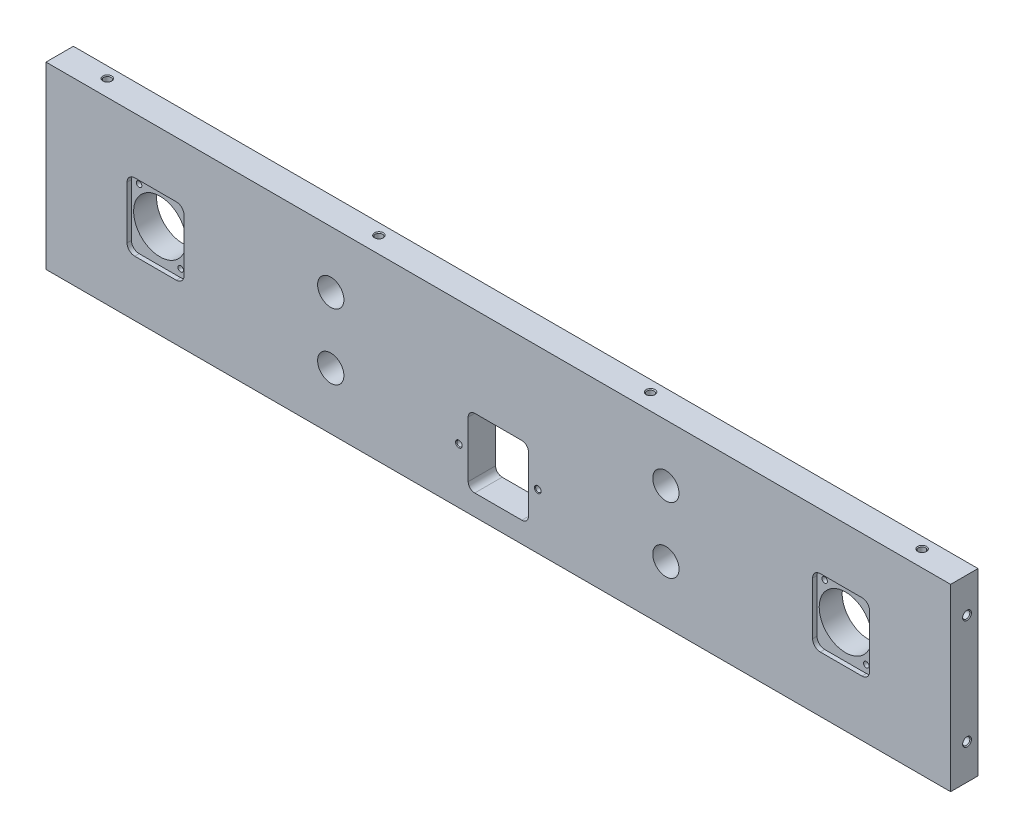
from build123d import *

# Parameters (mm, degrees)
SKETCH_1_W                   = 413
SKETCH_1_H                   = 82
EXTRUDE_1_DEPTH              = 12.5
SKETCH_2_R                   = 12
SKETCH_2_R_2                 = 6
SKETCH_2_W                   = 13.75
SKETCH_2_H                   = 31.5
CUT_EXTRUDE_1_DEPTH          = 13.5
HOLE_WIZARD_M3_1_D           = 2.5
HOLE_WIZARD_M3_1_CSINK_D     = 3.05
HOLE_WIZARD_M3_1_CSINK_ANGLE = 90
FILLET_1_R                   = 3
HOLE_WIZARD_M4_1_D           = 3.3
HOLE_WIZARD_M4_1_DEPTH       = 5
HOLE_WIZARD_M4_1_CSINK_D     = 4.05
HOLE_WIZARD_M4_1_CSINK_ANGLE = 90
HOLE_WIZARD_M4_1_TIP         = 0.991420021
HOLE_WIZARD_M4_2_D           = 3.3
HOLE_WIZARD_M4_2_DEPTH       = 5
HOLE_WIZARD_M4_2_CSINK_D     = 4.05
HOLE_WIZARD_M4_2_CSINK_ANGLE = 90
HOLE_WIZARD_M4_2_TIP         = 0.991420021
HOLE_WIZARD_M4_3_D           = 3.3
HOLE_WIZARD_M4_3_DEPTH       = 10.1
HOLE_WIZARD_M4_3_CSINK_D     = 4.05
HOLE_WIZARD_M4_3_CSINK_ANGLE = 90
HOLE_WIZARD_M4_3_TIP         = 0.991420021
HOLE_WIZARD_M4_4_D           = 3.3
HOLE_WIZARD_M4_4_DEPTH       = 10.1
HOLE_WIZARD_M4_4_CSINK_D     = 4.05
HOLE_WIZARD_M4_4_CSINK_ANGLE = 90
HOLE_WIZARD_M4_4_TIP         = 0.991420021
SKETCH_15_R                  = 12.5
CUT_EXTRUDE_2_DEPTH          = 3
SKETCH_16_W                  = 26
SKETCH_16_H                  = 31
CUT_EXTRUDE_3_DEPTH          = 2
FILLET_2_R                   = 3.5


with BuildPart() as part:
    # 草圖1 → 填料-伸長1 (new body)
    with BuildSketch(Plane.XY):
        with Locations((206.5, 41)):
            Rectangle(SKETCH_1_W, SKETCH_1_H)
    extrude(amount=EXTRUDE_1_DEPTH)

    # 草圖2 → 除料-伸長1 (cut, through all)
    with BuildSketch(Plane.XY.offset(12.5)):
        with Locations((50, 41)):
            Circle(SKETCH_2_R)
        with Locations((130, 56)):
            Circle(SKETCH_2_R_2)
        with Locations((130, 26)):
            Circle(SKETCH_2_R_2)
        with Locations((199.625, 25.25)):
            Rectangle(SKETCH_2_W, SKETCH_2_H)
        with Locations((213.375, 25.25)):
            Rectangle(SKETCH_2_W, SKETCH_2_H)
        with Locations((283, 56)):
            Circle(SKETCH_2_R_2)
        with Locations((283, 26)):
            Circle(SKETCH_2_R_2)
        with Locations((363, 41)):
            Circle(SKETCH_2_R)
    extrude(amount=-CUT_EXTRUDE_1_DEPTH, mode=Mode.SUBTRACT)

    # M3 螺紋孔1 (through all)
    with Locations(Plane.XY.offset(12.5)):
        with Locations((40.5, 53), (59.5, 29), (353.5, 53), (372.5, 29), (224.5, 25.25), (188.5, 25.25)):
            CounterSinkHole(HOLE_WIZARD_M3_1_D / 2, HOLE_WIZARD_M3_1_CSINK_D / 2, counter_sink_angle=HOLE_WIZARD_M3_1_CSINK_ANGLE)

    # 圓角1
    fillet_1_edges = [part.edges().sort_by_distance(p)[0] for p in [
        (192.75, 41, 6.25),
        (220.25, 41, 6.25),
        (220.25, 9.5, 6.25),
        (192.75, 9.5, 6.25),
    ]]
    fillet(fillet_1_edges, radius=FILLET_1_R)

    # M4 螺紋孔1
    with Locations(Plane(origin=(0, 82, 0), x_dir=(1, 0, 0), z_dir=(0, 1, 0))):
        with Locations((20.5, -5), (144.5, -5), (268.5, -5), (392.5, -5)):
            CounterSinkHole(HOLE_WIZARD_M4_1_D / 2, HOLE_WIZARD_M4_1_CSINK_D / 2, depth=HOLE_WIZARD_M4_1_DEPTH, counter_sink_angle=HOLE_WIZARD_M4_1_CSINK_ANGLE)
            with Locations((0, 0, -(HOLE_WIZARD_M4_1_DEPTH + HOLE_WIZARD_M4_1_TIP / 2))):  # 118° drill point
                Cone(0, HOLE_WIZARD_M4_1_D / 2, HOLE_WIZARD_M4_1_TIP, mode=Mode.SUBTRACT)

    # M4 螺紋孔2
    with Locations(Plane(origin=(0, 0, 0), x_dir=(-1, 0, 0), z_dir=(0, -1, 0))):
        with Locations((-144.5, -5), (-20.5, -5), (-268.5, -5), (-392.5, -5)):
            CounterSinkHole(HOLE_WIZARD_M4_2_D / 2, HOLE_WIZARD_M4_2_CSINK_D / 2, depth=HOLE_WIZARD_M4_2_DEPTH, counter_sink_angle=HOLE_WIZARD_M4_2_CSINK_ANGLE)
            with Locations((0, 0, -(HOLE_WIZARD_M4_2_DEPTH + HOLE_WIZARD_M4_2_TIP / 2))):  # 118° drill point
                Cone(0, HOLE_WIZARD_M4_2_D / 2, HOLE_WIZARD_M4_2_TIP, mode=Mode.SUBTRACT)

    # M4 螺紋孔3
    with Locations(Plane.ZY):
        with Locations((5, 66), (5, 16)):
            CounterSinkHole(HOLE_WIZARD_M4_3_D / 2, HOLE_WIZARD_M4_3_CSINK_D / 2, depth=HOLE_WIZARD_M4_3_DEPTH, counter_sink_angle=HOLE_WIZARD_M4_3_CSINK_ANGLE)
            with Locations((0, 0, -(HOLE_WIZARD_M4_3_DEPTH + HOLE_WIZARD_M4_3_TIP / 2))):  # 118° drill point
                Cone(0, HOLE_WIZARD_M4_3_D / 2, HOLE_WIZARD_M4_3_TIP, mode=Mode.SUBTRACT)

    # M4 螺紋孔4
    with Locations(Plane(origin=(413, 0, 0), x_dir=(0, 0, -1), z_dir=(1, 0, 0))):
        with Locations((-5, 66), (-5, 16)):
            CounterSinkHole(HOLE_WIZARD_M4_4_D / 2, HOLE_WIZARD_M4_4_CSINK_D / 2, depth=HOLE_WIZARD_M4_4_DEPTH, counter_sink_angle=HOLE_WIZARD_M4_4_CSINK_ANGLE)
            with Locations((0, 0, -(HOLE_WIZARD_M4_4_DEPTH + HOLE_WIZARD_M4_4_TIP / 2))):  # 118° drill point
                Cone(0, HOLE_WIZARD_M4_4_D / 2, HOLE_WIZARD_M4_4_TIP, mode=Mode.SUBTRACT)

    # 草圖15 → 除料-伸長2 (cut)
    with BuildSketch(Plane(origin=(0, 0, 0), x_dir=(-1, 0, 0), z_dir=(0, 0, -1))):
        with Locations((-283, 56)):
            Circle(SKETCH_15_R)
        with Locations((-283, 26)):
            Circle(SKETCH_15_R)
        with Locations((-130, 56)):
            Circle(SKETCH_15_R)
        with Locations((-130, 26)):
            Circle(SKETCH_15_R)
    extrude(amount=-CUT_EXTRUDE_2_DEPTH, mode=Mode.SUBTRACT)

    # 草圖16 → 除料-伸長3 (cut)
    with BuildSketch(Plane.XY.offset(12.5)):
        with Locations((50, 41)):
            Rectangle(SKETCH_16_W, SKETCH_16_H)
        with Locations((363, 41)):
            Rectangle(SKETCH_16_W, SKETCH_16_H)
    extrude(amount=-CUT_EXTRUDE_3_DEPTH, mode=Mode.SUBTRACT)

    # 圓角2
    fillet_2_edges = [part.edges().sort_by_distance(p)[0] for p in [
        (63, 56.5, 11.5),
        (63, 25.5, 11.5),
        (37, 25.5, 11.5),
        (37, 56.5, 11.5),
        (376, 56.5, 11.5),
        (376, 25.5, 11.5),
        (350, 25.5, 11.5),
        (350, 56.5, 11.5),
    ]]
    fillet(fillet_2_edges, radius=FILLET_2_R)


solid = part.part
